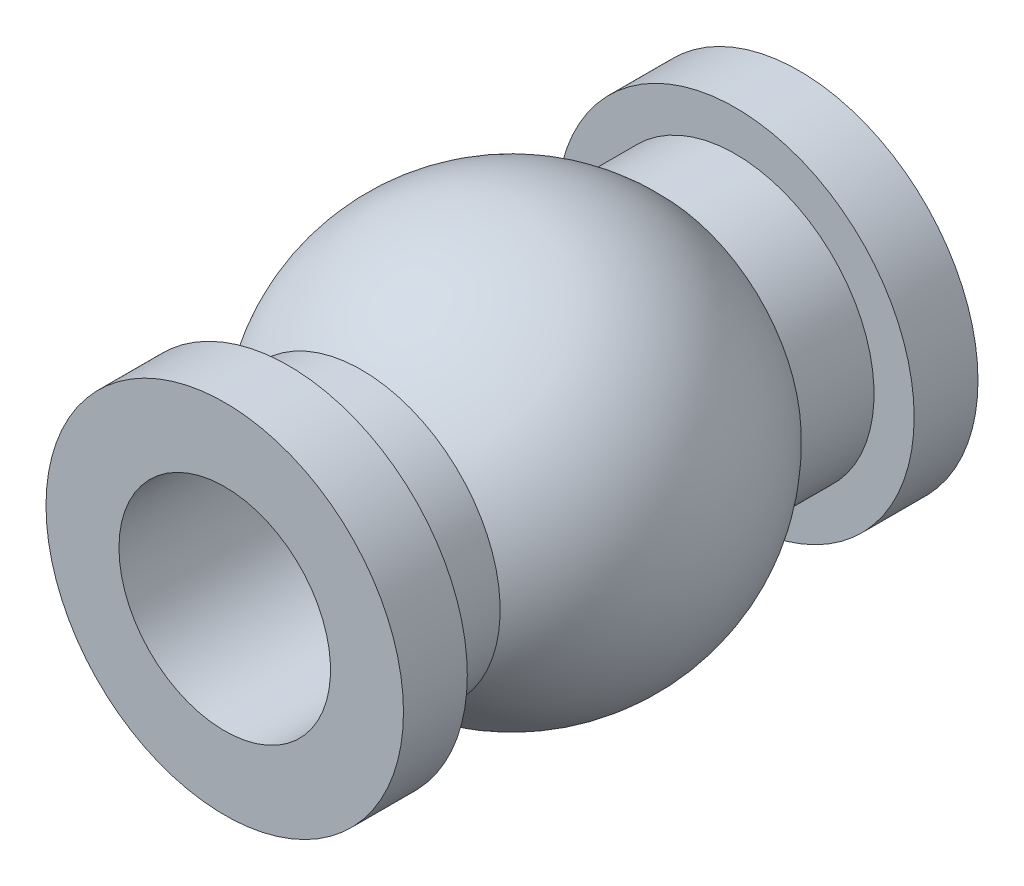
from build123d import *


with BuildPart() as part:
    # Sketch1 → Revolve1 (revolve)
    with BuildSketch(Plane(origin=(0, 0, 0), x_dir=(1, 0, 0), z_dir=(0, 1, 0))):
        with BuildLine():
            Line((1.4732, 4.0005), (1.4732, -4.0005))
            Line((1.4732, -4.0005), (2.4892, -4.0005))
            Line((2.4892, -4.0005), (2.4892, -3.1115))
            Line((2.4892, -3.1115), (1.9304, -3.1115))
            Line((1.9304, -3.1115), (1.9304, -2.0955))
            ThreePointArc((1.9304, -2.0955), (2.849133975, 0), (1.9304, 2.0955))
            Line((1.9304, 2.0955), (1.9304, 3.1115))
            Line((1.9304, 3.1115), (2.4892, 3.1115))
            Line((2.4892, 3.1115), (2.4892, 4.0005))
            Line((2.4892, 4.0005), (1.4732, 4.0005))
        make_face()
    revolve(axis=Axis((0, 0, -2.773013621), (0, 0, 1)))


solid = part.part
